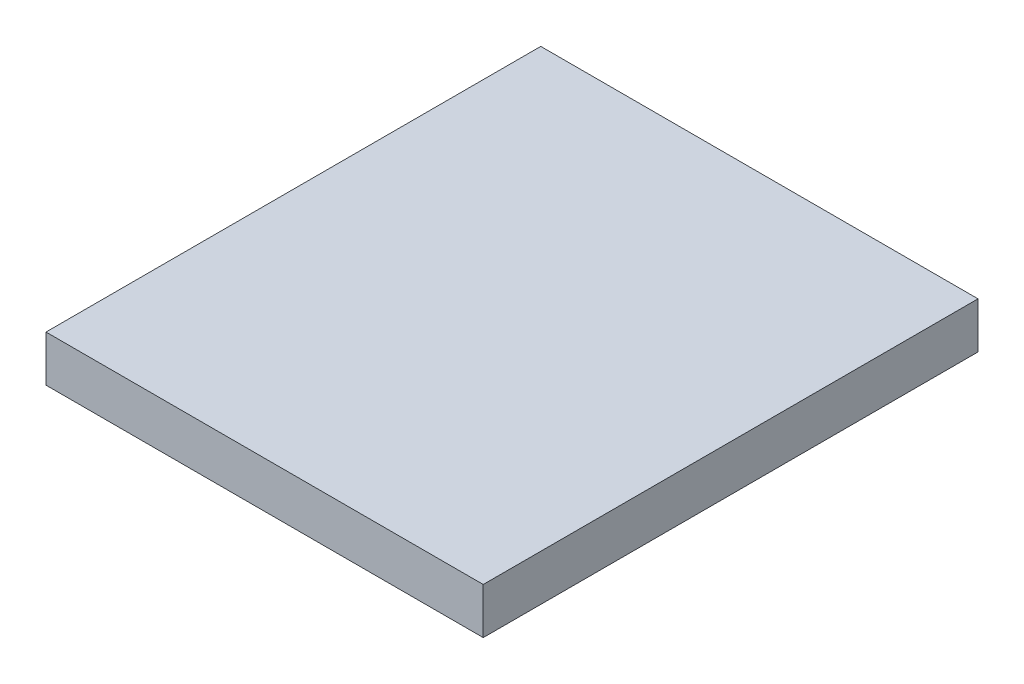
from build123d import *

# Parameters (mm, degrees)
SKETCH1_W           = 38
SKETCH1_H           = 43
BOSS_EXTRUDE1_DEPTH = 4


with BuildPart() as part:
    # Sketch1 → Boss-Extrude1 (new body)
    with BuildSketch(Plane(origin=(0, 0, 0), x_dir=(1, 0, 0), z_dir=(0, 1, 0))):
        with Locations((19, 21.5)):
            Rectangle(SKETCH1_W, SKETCH1_H)
    extrude(amount=BOSS_EXTRUDE1_DEPTH)


solid = part.part
